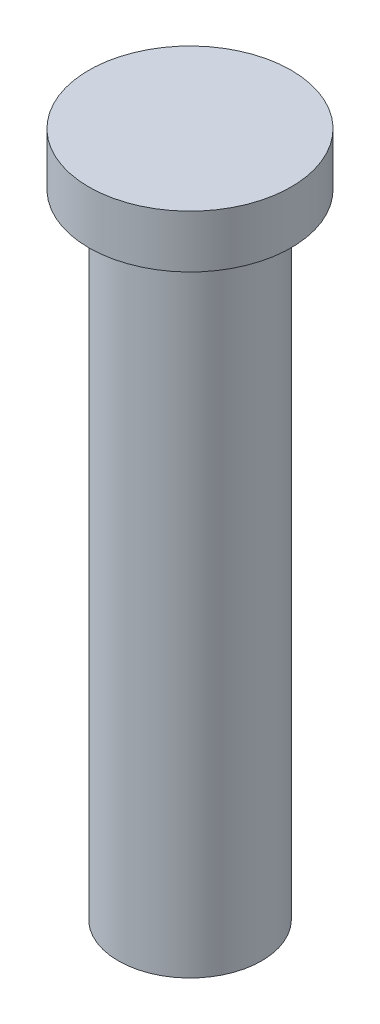
from build123d import *

# Parameters (mm, degrees)
SKETCH1_R           = 1.7
BOSS_EXTRUDE1_DEPTH = 15
SKETCH2_R           = 2.4
BOSS_EXTRUDE2_DEPTH = 1.25


with BuildPart() as part:
    # Sketch1 → Boss-Extrude1 (new body)
    with BuildSketch(Plane(origin=(0, 0, 0), x_dir=(1, 0, 0), z_dir=(0, 1, 0))):
        Circle(SKETCH1_R)
    extrude(amount=BOSS_EXTRUDE1_DEPTH)

    # Sketch2 → Boss-Extrude2 (add)
    with BuildSketch(Plane(origin=(0, 15, 0), x_dir=(1, 0, 0), z_dir=(0, 1, 0))):
        Circle(SKETCH2_R)
    extrude(amount=BOSS_EXTRUDE2_DEPTH)


solid = part.part
